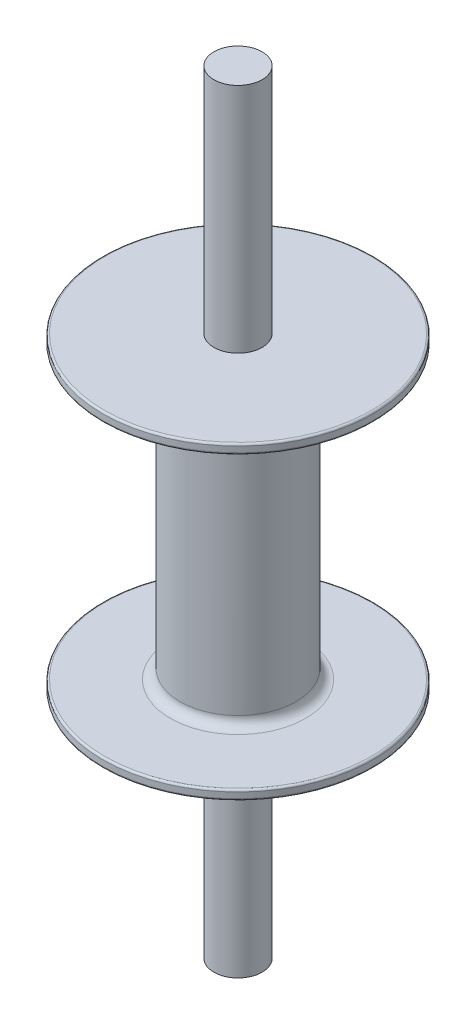
from build123d import *

# Parameters (mm, degrees)
BOSS_EXTRUDE1_DEPTH      = 150
BOSS_EXTRUDE1_DEPTH_BACK = 150
SKETCH1_R                = 60
SKETCH2_R                = 140
BOSS_EXTRUDE2_DEPTH      = 10
BOSS_EXTRUDE3_DEPTH      = 400
BOSS_EXTRUDE3_DEPTH_BACK = 400
SKETCH3_R                = 25
FILLET1_R                = 10
FILLET2_R                = 10
FILLET3_R                = 2
FILLET4_R                = 2
FILLET5_R                = 2
FILLET6_R                = 2


with BuildPart() as part:
    # Sketch1 → Boss-Extrude1 (new, two sides: drawn at the far end of the back side and taken through both)
    with BuildSketch(Plane(origin=(0, 0, 0), x_dir=(1, 0, 0), z_dir=(0, 1, 0)).offset(-BOSS_EXTRUDE1_DEPTH_BACK)):
        Circle(SKETCH1_R)
    extrude(amount=BOSS_EXTRUDE1_DEPTH + BOSS_EXTRUDE1_DEPTH_BACK)

    # Sketch2 → Boss-Extrude2 (add)
    with BuildSketch(Plane(origin=(0, 150, 0), x_dir=(1, 0, 0), z_dir=(0, 1, 0))):
        Circle(SKETCH2_R)
    boss_extrude2 = extrude(amount=BOSS_EXTRUDE2_DEPTH)

    # Mirror1: Boss-Extrude2 across plane
    add(boss_extrude2.mirror(Plane.ZX))

    # Sketch3 → Boss-Extrude3 (add, two sides: drawn at the far end of the back side and taken through both)
    with BuildSketch(Plane(origin=(0, 0, 0), x_dir=(1, 0, 0), z_dir=(0, 1, 0)).offset(-BOSS_EXTRUDE3_DEPTH_BACK)):
        Circle(SKETCH3_R)
    extrude(amount=BOSS_EXTRUDE3_DEPTH + BOSS_EXTRUDE3_DEPTH_BACK)

    # Fillet1
    fillet1_edges = [part.edges().sort_by_distance(p)[0] for p in [
        (-60, 150, 0),
    ]]
    fillet(fillet1_edges, radius=FILLET1_R)

    # Fillet2
    fillet2_edges = [part.edges().sort_by_distance(p)[0] for p in [
        (-60, -150, 0),
    ]]
    fillet(fillet2_edges, radius=FILLET2_R)

    # Fillet3
    fillet3_edges = [part.edges().sort_by_distance(p)[0] for p in [
        (-140, 150, 0),
    ]]
    fillet(fillet3_edges, radius=FILLET3_R)

    # Fillet4
    fillet4_edges = [part.edges().sort_by_distance(p)[0] for p in [
        (-140, -150, 0),
    ]]
    fillet(fillet4_edges, radius=FILLET4_R)

    # Fillet5
    fillet5_edges = [part.edges().sort_by_distance(p)[0] for p in [
        (-140, 160, 0),
    ]]
    fillet(fillet5_edges, radius=FILLET5_R)

    # Fillet6
    fillet6_edges = [part.edges().sort_by_distance(p)[0] for p in [
        (-140, -160, 0),
    ]]
    fillet(fillet6_edges, radius=FILLET6_R)


solid = part.part
